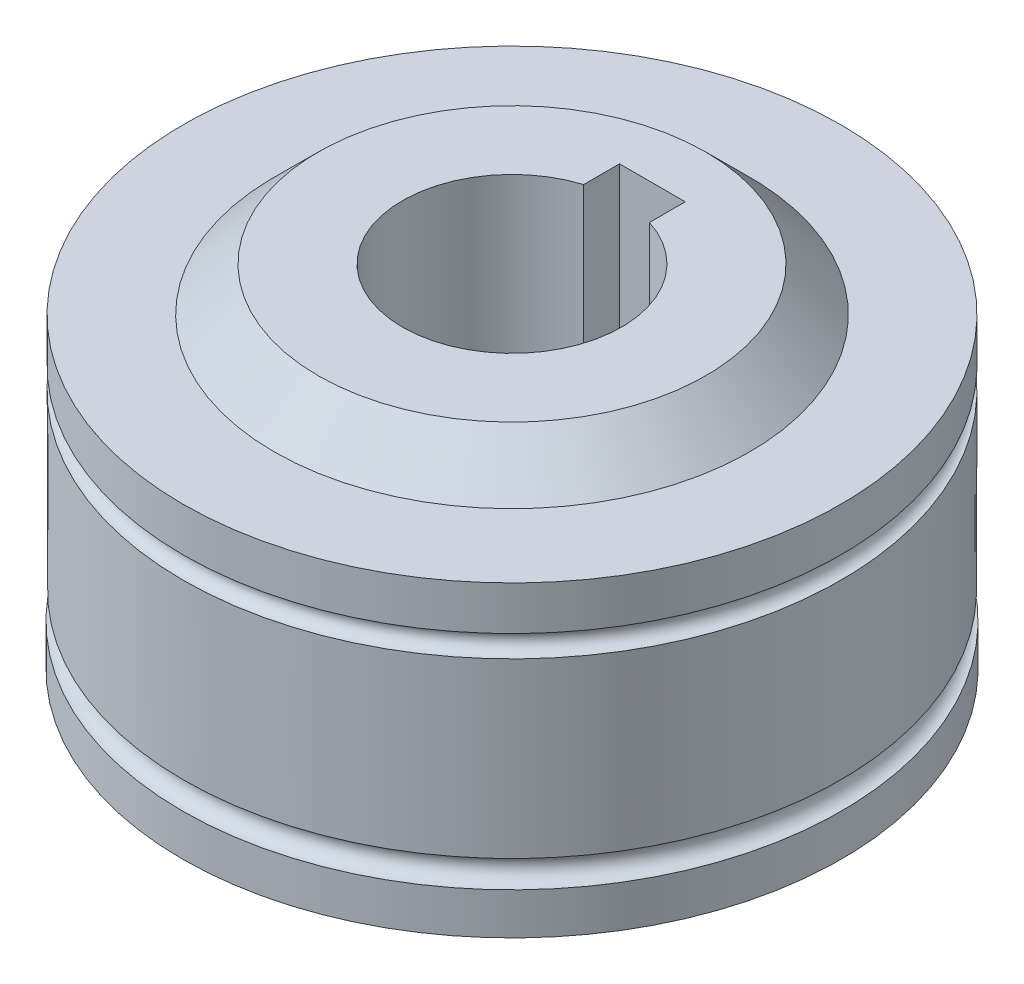
from build123d import *

# Parameters (mm, degrees)
SKETCH_2_W          = 3
SKETCH_2_H          = 2.405661247
CUT_EXTRUDE_1_DEPTH = 19


with BuildPart() as part:
    # Эскиз1 → Повернуть1 (revolve)
    with BuildSketch(Plane(origin=(0, 0, 0), x_dir=(0, 0, -1), z_dir=(1, 0, 0))):
        with BuildLine():
            Line((15, 7), (15, 5))
            ThreePointArc((15, 5), (14.5, 4.5), (15, 4))
            Line((15, 4), (14.982695469, -3.900561726))
            ThreePointArc((14.982695469, -3.900561726), (14.409213991, -4.525956797), (15.034609063, -5.099438274))
            Line((15.034609063, -5.099438274), (15.034609063, -7))
            Line((15.034609063, -7), (10.850882415, -7))
            Line((10.850882415, -7), (8.840023423, -9))
            Line((8.840023423, -9), (5, -9))
            Line((5, -9), (5, 9))
            Line((5, 9), (8.840023423, 9))
            Line((8.840023423, 9), (10.850882415, 7))
            Line((10.850882415, 7), (15, 7))
        make_face()
    revolve(axis=Axis((0, 26.633173064, 0), (0, -1, 0)))

    # Эскиз2 → Вырез-Вытянуть1 (cut, through all)
    with BuildSketch(Plane(origin=(0, 9, 0), x_dir=(1, 0, 0), z_dir=(0, 1, 0))):
        with Locations((0, 5.202830624)):
            Rectangle(SKETCH_2_W, SKETCH_2_H)
    extrude(amount=-CUT_EXTRUDE_1_DEPTH, mode=Mode.SUBTRACT)


solid = part.part
